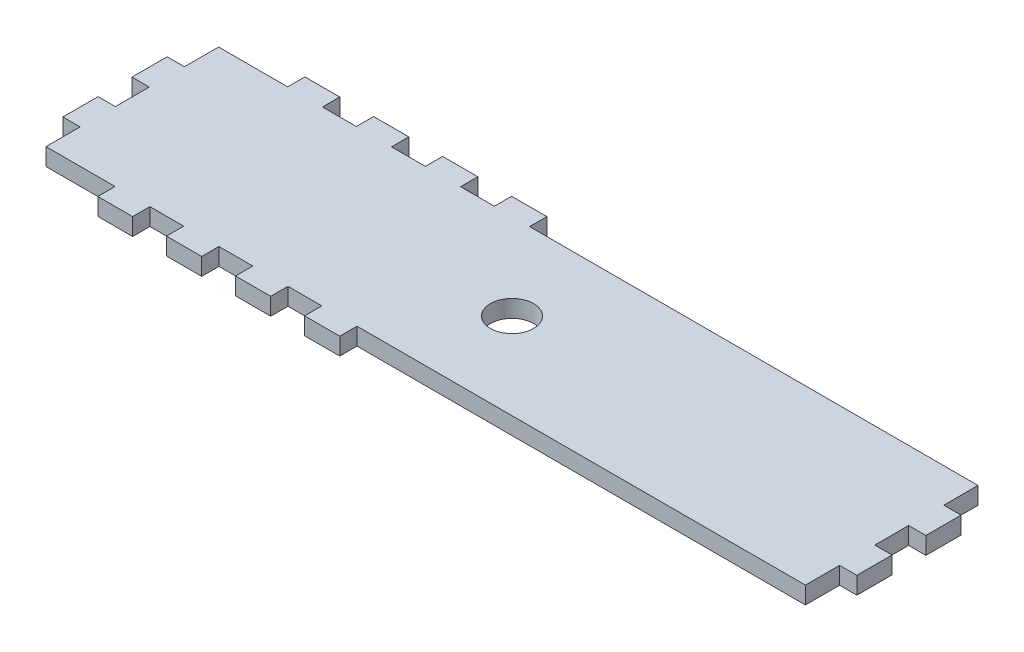
from build123d import *

# Parameters (mm, degrees)
SKETCH1_R           = 7.9375
BOSS_EXTRUDE1_DEPTH = 6.35


with BuildPart() as part:
    # Sketch1 → Boss-Extrude1 (new body)
    with BuildSketch(Plane(origin=(0, 0, 0), x_dir=(1, 0, 0), z_dir=(0, 1, 0))):
        Polygon((279.4, 0), (279.4, -12.573), (285.75, -12.573), (285.75, -25.527), (279.4, -25.527), (279.4, -37.973), (285.75, -37.973), (285.75, -50.927), (279.4, -50.927), (279.4, -63.5), (114.427, -63.5), (114.427, -69.85), (101.473, -69.85), (101.473, -63.5), (89.027, -63.5), (89.027, -69.85), (76.073, -69.85), (76.073, -63.5), (63.627, -63.5), (63.627, -69.85), (50.673, -69.85), (50.673, -63.5), (38.227, -63.5), (38.227, -69.85), (25.4, -69.85), (25.4, -63.5), (0, -63.5), (0, -50.927), (-6.35, -50.927), (-6.35, -37.973), (0, -37.973), (0, -25.527), (-6.35, -25.527), (-6.35, -12.573), (0, -12.573), (0, 0), (25.4, 0), (25.4, 6.35), (38.227, 6.35), (38.227, 0), (50.673, 0), (50.673, 6.35), (63.627, 6.35), (63.627, 0), (76.073, 0), (76.073, 6.35), (89.027, 6.35), (89.027, 0), (101.473, 0), (101.473, 6.35), (114.427, 6.35), (114.427, 0), align=None)
        with Locations((139.7, -31.75)):
            Circle(SKETCH1_R, mode=Mode.SUBTRACT)
    extrude(amount=BOSS_EXTRUDE1_DEPTH)


solid = part.part
